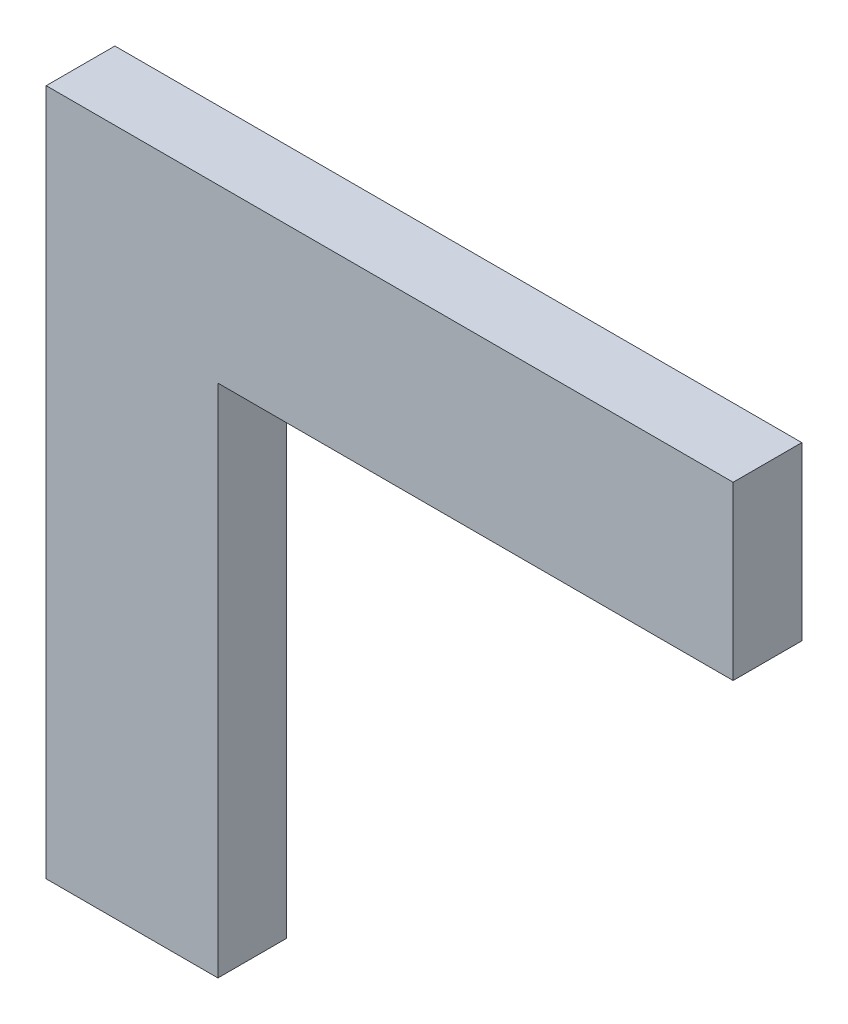
from build123d import *

# Parameters (mm, degrees)
BOSS_EXTRU_1_DEPTH = 8


with BuildPart() as part:
    # Esquisse1 → Boss.-Extru.1 (new body)
    with BuildSketch(Plane.XY):
        Polygon((0, 0), (0, 60), (60, 60), (60, 80), (-20, 80), (-20, 0), align=None)
    extrude(amount=BOSS_EXTRU_1_DEPTH)


solid = part.part
